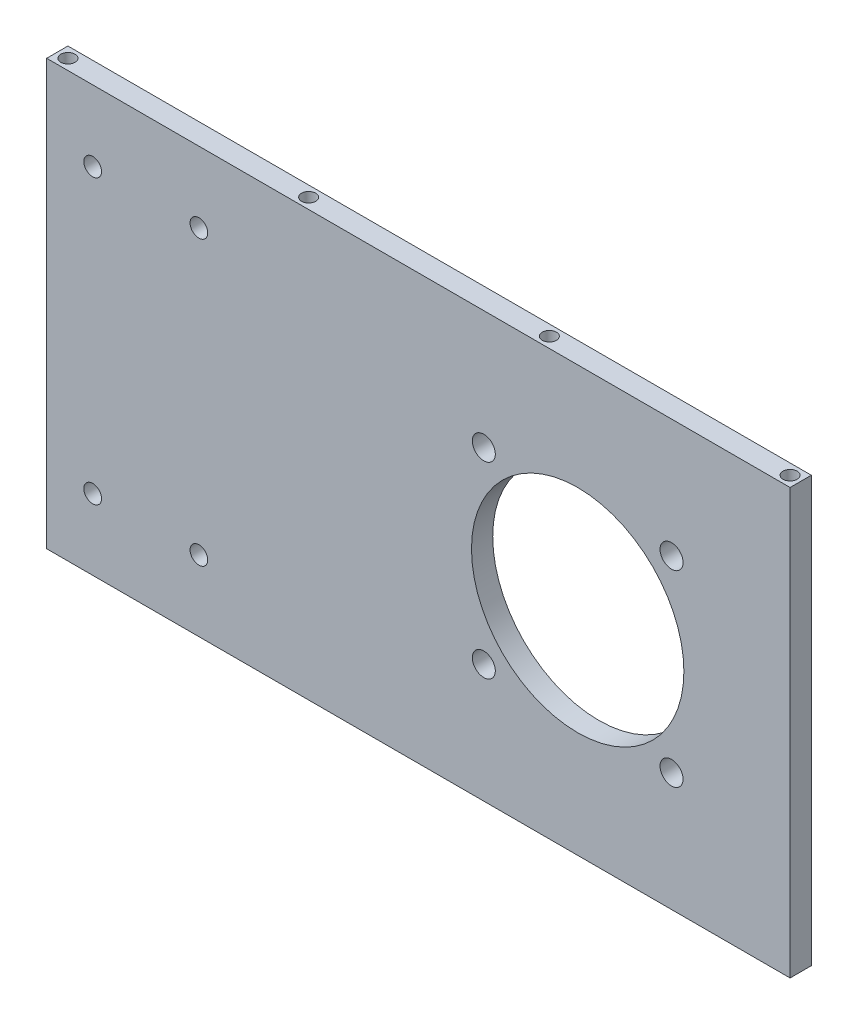
from build123d import *

# Parameters (mm, degrees)
SKETCH_1_W          = 210
SKETCH_1_H          = 120
SKETCH_1_R          = 3.25
SKETCH_1_R_2        = 30
EXTRUDE_1_DEPTH     = 6
SKETCH_2_R          = 2.5
CUT_EXTRUDE_1_DEPTH = 10
SKETCH_3_R          = 2
CUT_EXTRUDE_2_DEPTH = 20


with BuildPart() as part:
    # 草图1 → 凸台-拉伸1 (new body)
    with BuildSketch(Plane.XY):
        with Locations((-45, 0)):
            Rectangle(SKETCH_1_W, SKETCH_1_H)
        with Locations((26.516504294, 26.516504294)):
            Circle(SKETCH_1_R, mode=Mode.SUBTRACT)
        with Locations((26.516504294, -26.516504294)):
            Circle(SKETCH_1_R, mode=Mode.SUBTRACT)
        with Locations((-26.516504294, -26.516504294)):
            Circle(SKETCH_1_R, mode=Mode.SUBTRACT)
        with Locations((-26.516504294, 26.516504294)):
            Circle(SKETCH_1_R, mode=Mode.SUBTRACT)
        Circle(SKETCH_1_R_2, mode=Mode.SUBTRACT)
    extrude(amount=EXTRUDE_1_DEPTH)

    # 草图2 → 切除-拉伸1 (cut)
    with BuildSketch(Plane.XY.offset(6)):
        with Locations((-137, 40)):
            Circle(SKETCH_2_R)
        with Locations((-107, 40)):
            Circle(SKETCH_2_R)
        with Locations((-107, -40)):
            Circle(SKETCH_2_R)
        with Locations((-137, -40)):
            Circle(SKETCH_2_R)
    extrude(amount=-CUT_EXTRUDE_1_DEPTH, mode=Mode.SUBTRACT)

    # 草图3 → 切除-拉伸2 (cut)
    with BuildSketch(Plane(origin=(0, -60, 0), x_dir=(-1, 0, 0), z_dir=(0, -1, 0))):
        with Locations((-57, -3)):
            Circle(SKETCH_3_R)
        with Locations((11, -3)):
            Circle(SKETCH_3_R)
        with Locations((79, -3)):
            Circle(SKETCH_3_R)
        with Locations((147, -3)):
            Circle(SKETCH_3_R)
    cut_extrude_2 = extrude(amount=-CUT_EXTRUDE_2_DEPTH, mode=Mode.SUBTRACT)

    # 镜向3: 切除-拉伸2 across plane
    add(cut_extrude_2.mirror(Plane(origin=(0, 0, 0), x_dir=(0, 0, 1), z_dir=(0, -1, 0))), mode=Mode.SUBTRACT)


solid = part.part
